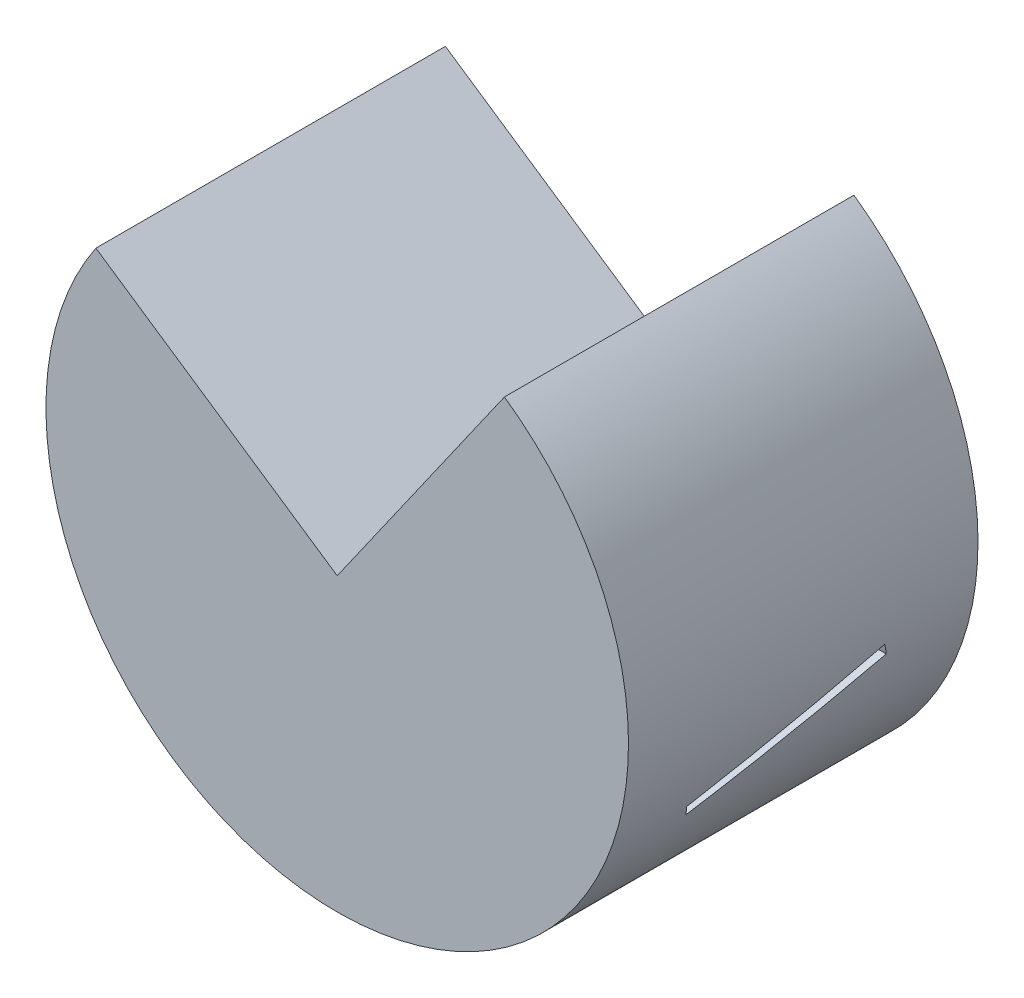
from build123d import *

# Parameters (mm, degrees)
SKETCH1_R                    = 25
BOSS_EXTRUDE1_DEPTH          = 15
CUT_EXTRUDE1_DEPTH           = 30
CUT_EXTRUDE_THIN3_DEPTH      = 26
CUT_EXTRUDE_THIN3_DEPTH_BACK = 26


with BuildPart() as part:
    # Sketch1 → Boss-Extrude1 (new body, symmetric)
    with BuildSketch(Plane.XY):
        Circle(SKETCH1_R)
    extrude(amount=BOSS_EXTRUDE1_DEPTH, both=True)

    # Sketch2 → Cut-Extrude1 (cut)
    with BuildSketch(Plane.XY.offset(15)):
        Polygon((-128.64988892, 86.933618644), (-20.714125317, 13.997321614), (0, 0), (14.35317498, 20.469156504), (89.143728668, 127.128453183), (41.85899915, 383.338297472), (-175.934618438, 343.143462933), align=None)
    extrude(amount=-CUT_EXTRUDE1_DEPTH, mode=Mode.SUBTRACT)

    # Sketch4 → Cut-Extrude-Thin3 (cut, two sides)
    with BuildSketch(Plane(origin=(0, 0, 0), x_dir=(0, 0, -1), z_dir=(1, 0, 0))) as cut_extrude_thin3_sk:
        Polygon((-8.132669534, -9.679737666), (7.600765094, -4.847746507), (7.30718246, -3.891812808), (-8.426252168, -8.723803967), align=None)
    extrude(amount=CUT_EXTRUDE_THIN3_DEPTH, mode=Mode.SUBTRACT)
    extrude(cut_extrude_thin3_sk.sketch, amount=-CUT_EXTRUDE_THIN3_DEPTH_BACK, mode=Mode.SUBTRACT)


solid = part.part
